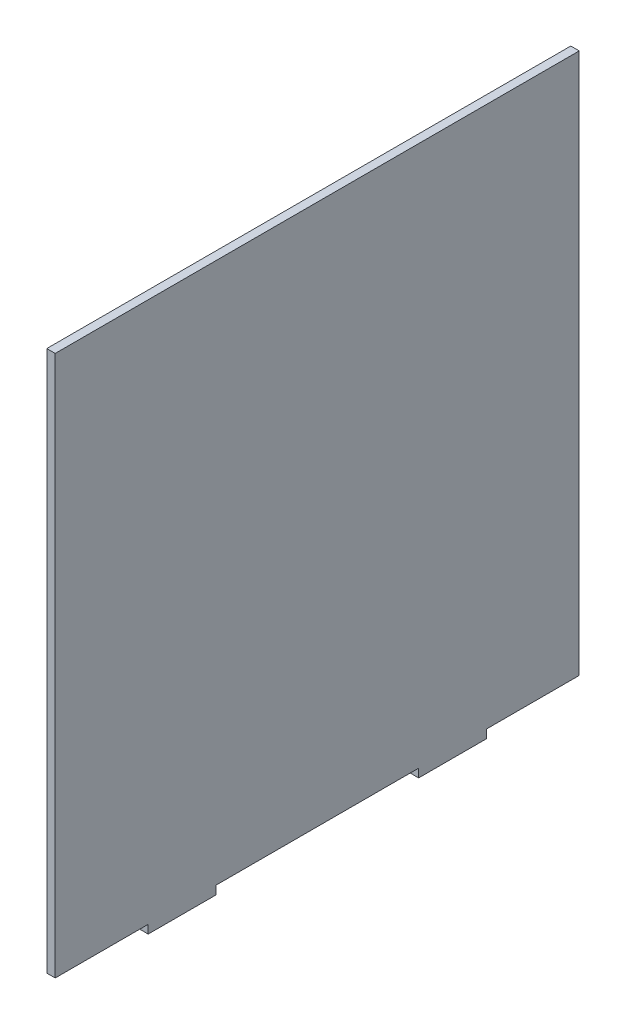
from build123d import *

# Parameters (mm, degrees)
SKETCH1_W           = 196.85
SKETCH1_H           = 203.2
BOSS_EXTRUDE1_DEPTH = 3.175
SKETCH3_W           = 3.175
SKETCH3_H           = 25.4
BOSS_EXTRUDE2_DEPTH = 3.175


with BuildPart() as part:
    # Sketch1 → Boss-Extrude1 (new body)
    with BuildSketch(Plane(origin=(0, 0, 0), x_dir=(0, 0, -1), z_dir=(1, 0, 0))):
        with Locations((98.425, 101.6)):
            Rectangle(SKETCH1_W, SKETCH1_H)
    extrude(amount=BOSS_EXTRUDE1_DEPTH)

    # Sketch3 → Boss-Extrude2 (add)
    with BuildSketch(Plane.XZ):
        with Locations((1.5875, -47.625)):
            Rectangle(SKETCH3_W, SKETCH3_H)
        with Locations((1.5875, -149.225)):
            Rectangle(SKETCH3_W, SKETCH3_H)
    extrude(amount=BOSS_EXTRUDE2_DEPTH)


solid = part.part
